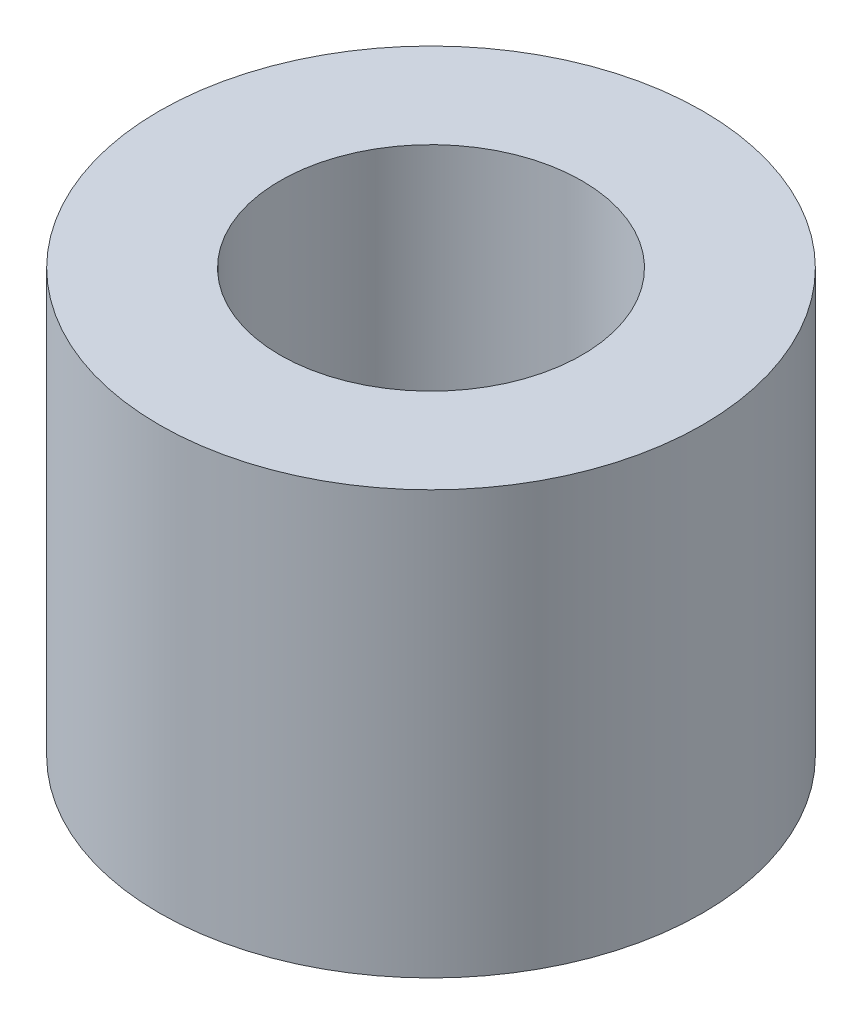
from build123d import *

# Parameters (mm, degrees)
SKETCH_1_R      = 4.5
SKETCH_1_R_2    = 2.5
EXTRUDE_1_DEPTH = 7


with BuildPart() as part:
    # 草图1 → 凸台-拉伸1 (new body)
    with BuildSketch(Plane(origin=(0, 0, 0), x_dir=(1, 0, 0), z_dir=(0, 1, 0))):
        Circle(SKETCH_1_R)
        Circle(SKETCH_1_R_2, mode=Mode.SUBTRACT)
    extrude(amount=EXTRUDE_1_DEPTH)


solid = part.part
